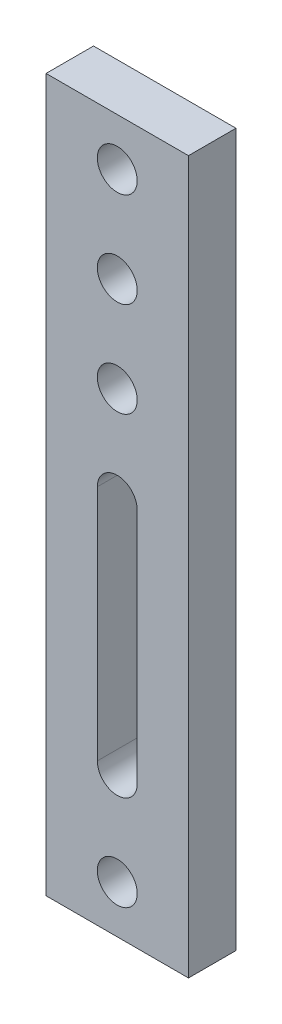
from build123d import *

# Parameters (mm, degrees)
SKETCH_1_W          = 75
SKETCH_1_H          = 375
EXTRUDE_1_DEPTH     = 25
SKETCH_2_R          = 10.5
CUT_EXTRUDE_1_DEPTH = 26


with BuildPart() as part:
    # Эскиз1 → Бобышка-Вытянуть1 (new body)
    with BuildSketch(Plane.XY):
        with Locations((37.5, 187.5)):
            Rectangle(SKETCH_1_W, SKETCH_1_H)
    extrude(amount=EXTRUDE_1_DEPTH)

    # Эскиз2 → Вырез-Вытянуть1 (cut, through all)
    with BuildSketch(Plane.XY.offset(25)):
        with Locations((37.5, 250)):
            Circle(SKETCH_2_R)
        with Locations((37.5, 300)):
            Circle(SKETCH_2_R)
        with Locations((37.5, 350)):
            Circle(SKETCH_2_R)
        with Locations((37.5, 25)):
            Circle(SKETCH_2_R)
        with BuildLine():
            Line((27, 75), (27, 200))
            ThreePointArc((27, 200), (37.5, 210.5), (48, 200))
            Line((48, 200), (48, 75))
            ThreePointArc((48, 75), (37.5, 64.5), (27, 75))
        make_face()
    extrude(amount=-CUT_EXTRUDE_1_DEPTH, mode=Mode.SUBTRACT)


solid = part.part
